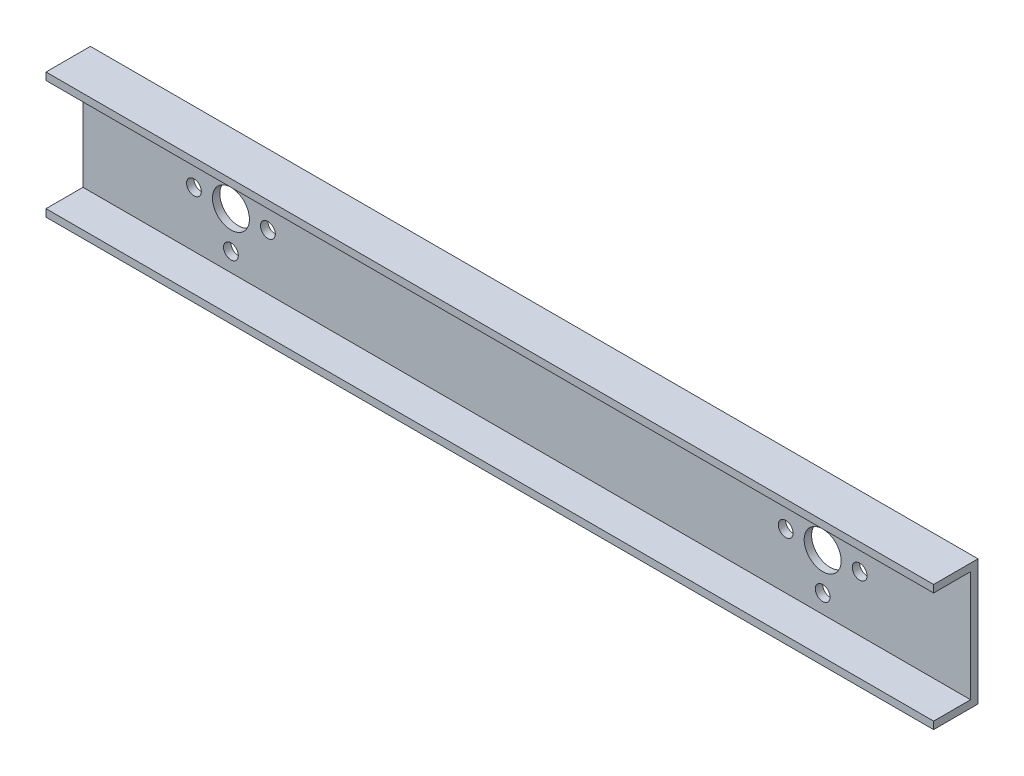
from build123d import *

# Parameters (mm, degrees)
BOSS_EXTRUDE2_DEPTH = 1200
SKETCH2_R           = 25
SKETCH2_R_2         = 10
CUT_EXTRUDE1_DEPTH  = 1200


with BuildPart() as part:
    # Sketch1 → Boss-Extrude2 (new body)
    with BuildSketch(Plane(origin=(0, 0, 0), x_dir=(0, 0, -1), z_dir=(1, 0, 0))):
        Polygon((-25, 75), (-25, 85), (35, 85), (35, -85), (-25, -85), (-25, -75), (25, -75), (25, 75), align=None)
    extrude(amount=BOSS_EXTRUDE2_DEPTH)

    # Sketch2 → Cut-Extrude1 (cut)
    with BuildSketch(Plane.XY.offset(-25)):
        with Locations((1000, 0)):
            Circle(SKETCH2_R)
        with Locations((950, 0)):
            Circle(SKETCH2_R_2)
        with Locations((1000, 50)):
            Circle(SKETCH2_R_2)
        with Locations((1000, -50)):
            Circle(SKETCH2_R_2)
        with Locations((1050, 0)):
            Circle(SKETCH2_R_2)
    cut_extrude1 = extrude(amount=-CUT_EXTRUDE1_DEPTH, mode=Mode.SUBTRACT)

    # Mirror2: Cut-Extrude1 across plane
    add(cut_extrude1.mirror(Plane(origin=(600, 0, 0), x_dir=(0, 0, 1), z_dir=(1, 0, 0))), mode=Mode.SUBTRACT)


solid = part.part
